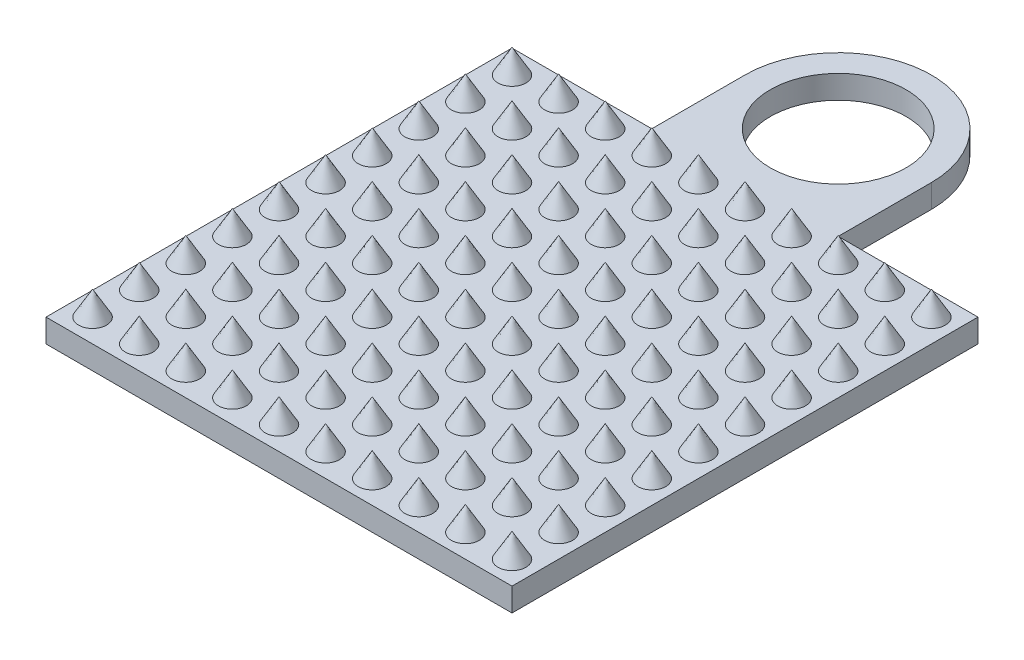
from build123d import *

# Parameters (mm, degrees)
SKETCH1_W               = 10
SKETCH1_H               = 10
PLATE_DEPTH             = 0.5
BOSS_EXTRUDE3_DEPTH     = 0.5
CUT_EXTRUDE1_DEPTH      = 0.5
CUT_EXTRUDE1_DEPTH_BACK = 1.5
SKETCH5_R               = 1.455938962
LPATTERN1_COUNT         = 10
LPATTERN1_PITCH         = 1
LPATTERN1_COUNT_DIR2    = 10
LPATTERN1_PITCH_DIR2    = 1


with BuildPart() as part:
    # Sketch1 → Plate (new body)
    with BuildSketch(Plane(origin=(0, 0, 0), x_dir=(1, 0, 0), z_dir=(0, 1, 0))):
        Rectangle(SKETCH1_W, SKETCH1_H)
    extrude(amount=PLATE_DEPTH)

    # Sketch4 → Boss-Extrude3 (add)
    with BuildSketch(Plane(origin=(0, 0, 0), x_dir=(1, 0, 0), z_dir=(0, 1, 0))):
        with BuildLine():
            Line((-2, 7), (-2, 5))
            Line((-2, 5), (2, 5))
            Line((2, 5), (2, 7))
            ThreePointArc((2, 7), (0, 9), (-2, 7))
        make_face()
    extrude(amount=BOSS_EXTRUDE3_DEPTH)

    # Sketch5 → Cut-Extrude1 (cut, two sides: drawn at the far end of the back side and taken through both)
    with BuildSketch(Plane(origin=(0, 0.5, 0), x_dir=(1, 0, 0), z_dir=(0, 1, 0)).offset(-CUT_EXTRUDE1_DEPTH_BACK)):
        with Locations(Location((0, 7, 0), (0, 0, 270))):
            Circle(SKETCH5_R)
    extrude(amount=CUT_EXTRUDE1_DEPTH + CUT_EXTRUDE1_DEPTH_BACK, mode=Mode.SUBTRACT)

    # Cone cone 1 section (through the dimple's axis) → Cone (revolve)
    with BuildSketch(Plane(origin=(-4.5, 0.5, 4.5), x_dir=(0, 0, -1), z_dir=(1, 0, 0))):
        Polygon((0, 0), (0.3, 0), (0, 0.519615242), align=None)
    cone = revolve(axis=Axis((-4.5, 0.5, 4.5), (0, 1, 0)))

    # LPattern1: Cone 10 × 10
    with Locations(*[(i * LPATTERN1_PITCH, 0, -j * LPATTERN1_PITCH_DIR2) for i in range(LPATTERN1_COUNT) for j in range(LPATTERN1_COUNT_DIR2) if (i, j) != (0, 0)]):
        add(cone)


solid = part.part
